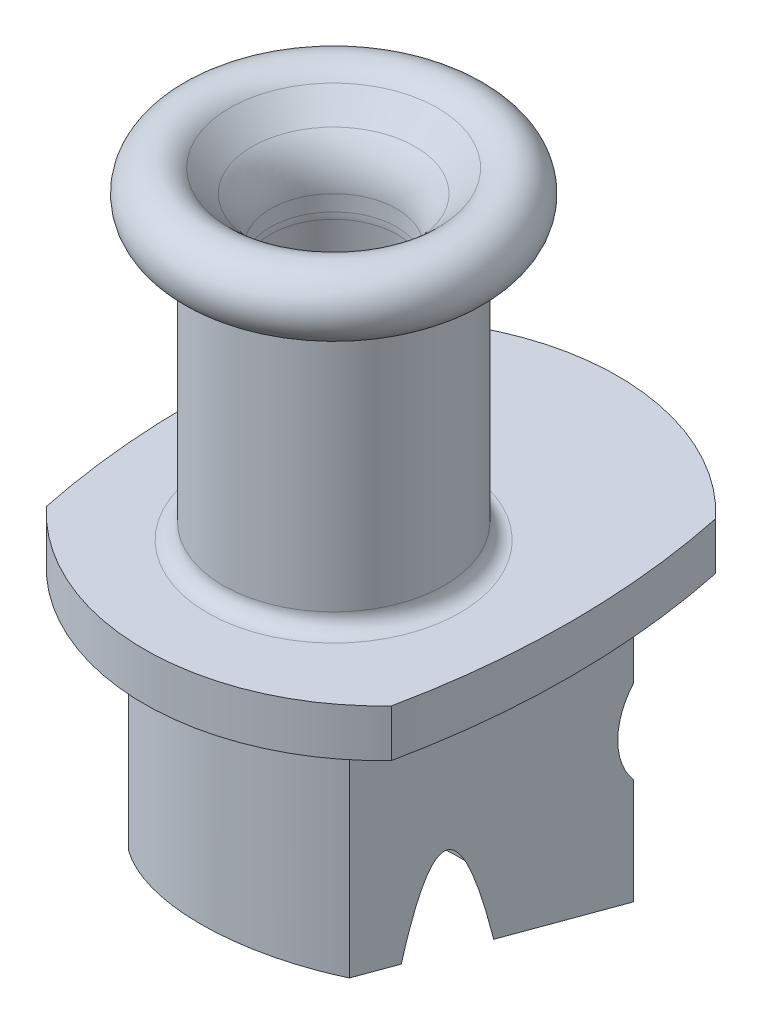
from build123d import *

# Parameters (mm, degrees)
SKETCH2_OUTSIDE_W  = 29.166
SKETCH2_OUTSIDE_H  = 29.166
CUT_EXTRUDE1_DEPTH = 12.5
SKETCH3_OUTSIDE_W  = 19.842
SKETCH3_OUTSIDE_H  = 22.842
CUT_EXTRUDE2_DEPTH = 11
SKETCH4_R          = 2
CUT_EXTRUDE3_DEPTH = 5
SKETCH5_R          = 1.25
CUT_EXTRUDE4_DEPTH = 10


with BuildPart() as part:
    # Sketch1 → Revolve1 (revolve)
    with BuildSketch(Plane.XY, mode=Mode.PRIVATE) as revolve1_sk:
        with BuildLine():
            Line((2, 0), (2, -0.5))
            ThreePointArc((2, -0.5), (2.00274093, -0.604671912), (2.010956209, -0.709056927))
            Line((2.010956209, -0.709056927), (3.994980429, -19.585786438))
            Line((3.994980429, -19.585786438), (8, -19.585786438))
            Line((8, -19.585786438), (8, -9.585786438))
            Line((8, -9.585786438), (10, -9.585786438))
            Line((10, -9.585786438), (10, -8.085786438))
            Line((10, -8.085786438), (4, -8.085786438))
            ThreePointArc((4, -8.085786438), (3.646446609, -7.939339828), (3.5, -7.585786438))
            Line((3.5, -7.585786438), (3.5, -0.085786438))
            ThreePointArc((3.5, -0.085786438), (3.646446609, 0.267766953), (4, 0.414213562))
            ThreePointArc((4, 0.414213562), (4.923879533, 1.796896995), (3.292893219, 2.121320344))
            Line((3.292893219, 2.121320344), (2.585786438, 1.414213562))
            ThreePointArc((2.585786438, 1.414213562), (2.152240935, 0.765366865), (2, 0))
        make_face()
    revolve(revolve1_sk.sketch.rotate(Axis((0, -19.635786438, 0), (0, 1, 0)), 90), axis=Axis((0, -19.635786438, 0), (0, 1, 0)))  # turned: the seam where the file's is

    # Sketch2 outside → Cut-Extrude1 (cut, through all)
    with BuildSketch(Plane(origin=(0, -8.085786438, 0), x_dir=(-1, 0, 0), z_dir=(0, 1, 0))):
        Rectangle(SKETCH2_OUTSIDE_W, SKETCH2_OUTSIDE_H)
        with BuildLine():
            ThreePointArc((5.467105263, 3.634273078), (0, 6), (-5.467105263, 3.634273078))
            ThreePointArc((-5.467105263, 3.634273078), (-6, -1.5), (-5.467105263, -6.634273078))
            ThreePointArc((-5.467105263, -6.634273078), (0, -9), (5.467105263, -6.634273078))
            ThreePointArc((5.467105263, -6.634273078), (6, -1.5), (5.467105263, 3.634273078))
        make_face(mode=Mode.SUBTRACT)
    extrude(amount=-CUT_EXTRUDE1_DEPTH, mode=Mode.SUBTRACT)

    # Sketch3 outside → Cut-Extrude2 (cut, through all)
    with BuildSketch(Plane.XZ.offset(9.585786438)):
        with Locations((0, -1.5)):
            Rectangle(SKETCH3_OUTSIDE_W, SKETCH3_OUTSIDE_H)
        with BuildLine():
            Line((-3.5, -6), (-3.5, 3))
            ThreePointArc((-3.5, 3), (0, 4.200877125), (3.5, 3))
            Line((3.5, 3), (3.5, -6))
            ThreePointArc((3.5, -6), (0, -7.200877125), (-3.5, -6))
        make_face(mode=Mode.SUBTRACT)
    extrude(amount=CUT_EXTRUDE2_DEPTH, mode=Mode.SUBTRACT)

    # Sketch4 → Cut-Extrude3 (cut, symmetric)
    with BuildSketch(Plane(origin=(0, 0, 0), x_dir=(0, 0, -1), z_dir=(1, 0, 0))):
        with Locations((7.5, -14.585786438)):
            Circle(SKETCH4_R)
        Polygon((-4.200877125, -16.530695594), (7.200877125, -19.585786438), (-4.200877125, -19.585786438), align=None)
    extrude(amount=CUT_EXTRUDE3_DEPTH, both=True, mode=Mode.SUBTRACT)

    # Sketch5 → Cut-Extrude4 (cut, through all)
    with BuildSketch(Plane.XY):
        with Locations((0, -14.585786438)):
            Circle(SKETCH5_R)
    extrude(amount=-CUT_EXTRUDE4_DEPTH, mode=Mode.SUBTRACT)


solid = part.part
